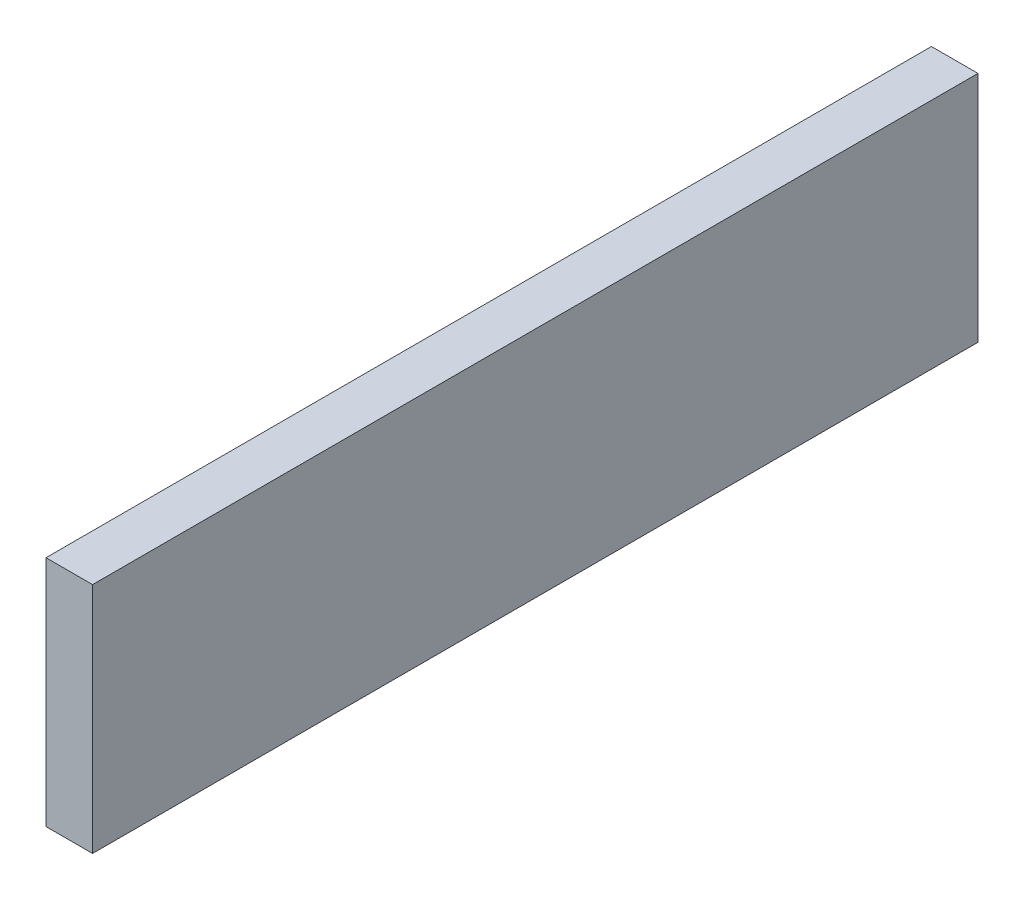
from build123d import *

# Parameters (mm, degrees)
SKETCH_1_W      = 157.8
SKETCH_1_H      = 789
EXTRUDE_1_DEPTH = 3000


with BuildPart() as part:
    # Эскиз1 → Вытянуть1 (new body)
    with BuildSketch(Plane.XY):
        with Locations((394.5, 394.5)):
            Rectangle(SKETCH_1_W, SKETCH_1_H)
    extrude(amount=-EXTRUDE_1_DEPTH)


solid = part.part
